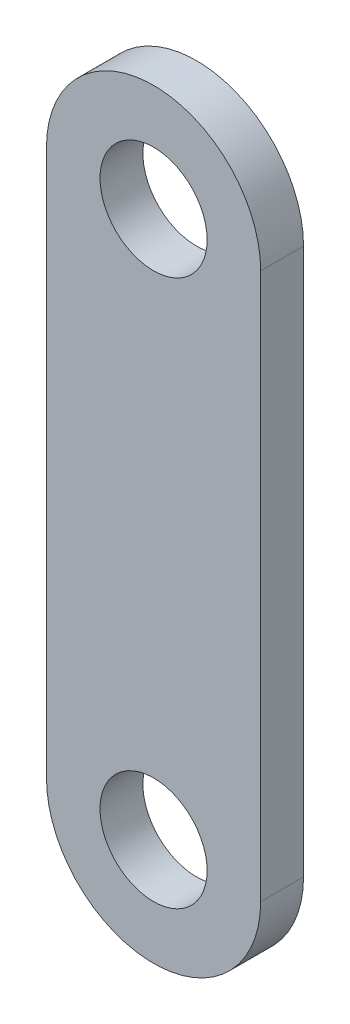
from build123d import *

# Parameters (mm, degrees)
BOSS_EXTRUDE1_DEPTH = 20
SKETCH2_R           = 25
CUT_EXTRUDE1_DEPTH  = 20


with BuildPart() as part:
    # Sketch1 → Boss-Extrude1 (new body)
    with BuildSketch(Plane.XY):
        with BuildLine():
            Line((50, -127.5), (50, 127.5))
            ThreePointArc((50, 127.5), (0, 177.5), (-50, 127.5))
            Line((-50, 127.5), (-50, -127.5))
            ThreePointArc((-50, -127.5), (0, -177.5), (50, -127.5))
        make_face()
    extrude(amount=BOSS_EXTRUDE1_DEPTH)

    # Sketch2 → Cut-Extrude1 (cut)
    with BuildSketch(Plane.XY.offset(20)):
        with Locations((0, 127.5)):
            Circle(SKETCH2_R)
        with Locations((0, -127.5)):
            Circle(SKETCH2_R)
    extrude(amount=-CUT_EXTRUDE1_DEPTH, mode=Mode.SUBTRACT)


solid = part.part
